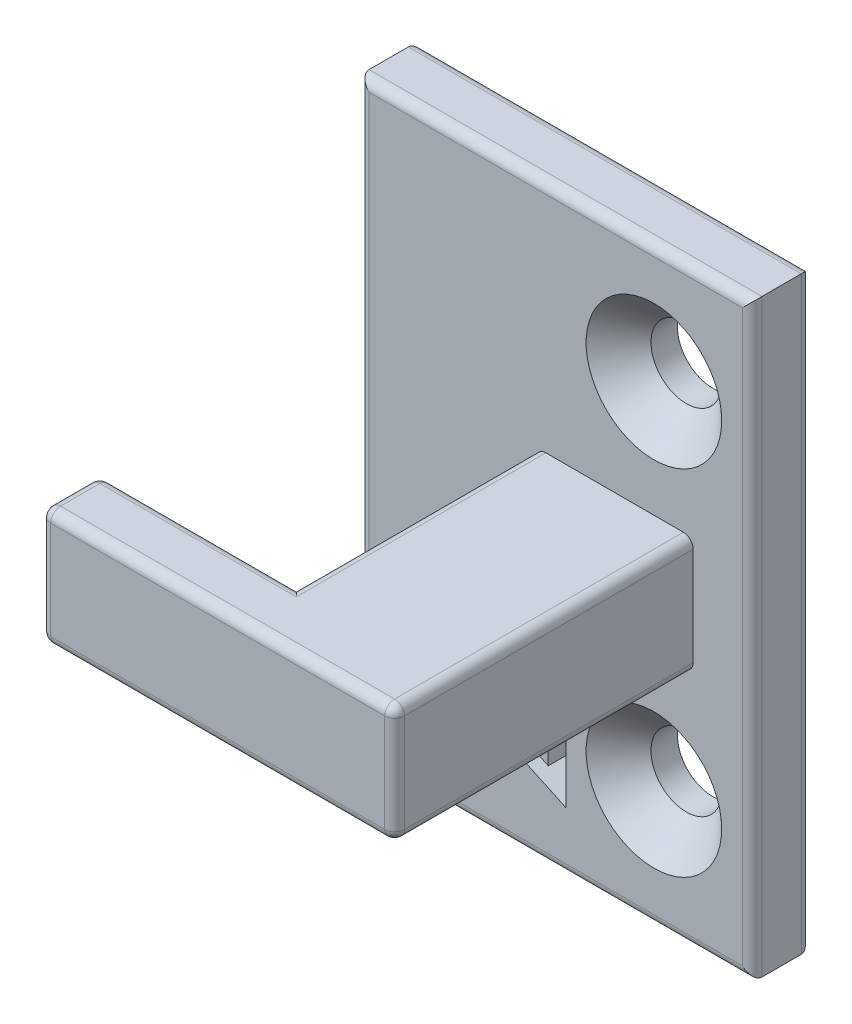
from build123d import *

# Parameters (mm, degrees)
SKETCH1_W                                           = 20
SKETCH1_H                                           = 30
BOSS_EXTRUDE1_DEPTH                                 = 3
CSK_FOR_M3_COUNTERSUNK_FLAT_HEAD_SCREW1_D           = 3.6
CSK_FOR_M3_COUNTERSUNK_FLAT_HEAD_SCREW1_DEPTH       = 20
CSK_FOR_M3_COUNTERSUNK_FLAT_HEAD_SCREW1_CSINK_D     = 6.9
CSK_FOR_M3_COUNTERSUNK_FLAT_HEAD_SCREW1_CSINK_ANGLE = 90
CSK_FOR_M3_COUNTERSUNK_FLAT_HEAD_SCREW1_TIP         = 1.081549114
SKETCH4_W                                           = 8
SKETCH4_H                                           = 6
BOSS_EXTRUDE2_DEPTH                                 = 15.2
SKETCH5_W                                           = 3
SKETCH5_H                                           = 6
BOSS_EXTRUDE3_DEPTH                                 = 10
FILLET2_R                                           = 0.5
CUT_EXTRUDE1_DEPTH                                  = 4
FILLET3_R                                           = 0.5


with BuildPart() as part:
    # Sketch1 → Boss-Extrude1 (new body)
    with BuildSketch(Plane.XY):
        Rectangle(SKETCH1_W, SKETCH1_H)
    extrude(amount=BOSS_EXTRUDE1_DEPTH)

    # CSK for M3 Countersunk Flat Head Screw1
    with Locations(Plane(origin=(5, 9, 3), x_dir=(1, 0, 0), z_dir=(0, 0, 1))):
        with Locations((0, 0), (0, -18)):
            CounterSinkHole(CSK_FOR_M3_COUNTERSUNK_FLAT_HEAD_SCREW1_D / 2, CSK_FOR_M3_COUNTERSUNK_FLAT_HEAD_SCREW1_CSINK_D / 2, depth=CSK_FOR_M3_COUNTERSUNK_FLAT_HEAD_SCREW1_DEPTH, counter_sink_angle=CSK_FOR_M3_COUNTERSUNK_FLAT_HEAD_SCREW1_CSINK_ANGLE)
            with Locations((0, 0, -(CSK_FOR_M3_COUNTERSUNK_FLAT_HEAD_SCREW1_DEPTH + CSK_FOR_M3_COUNTERSUNK_FLAT_HEAD_SCREW1_TIP / 2))):  # 118° drill point
                Cone(0, CSK_FOR_M3_COUNTERSUNK_FLAT_HEAD_SCREW1_D / 2, CSK_FOR_M3_COUNTERSUNK_FLAT_HEAD_SCREW1_TIP, mode=Mode.SUBTRACT)

    # Sketch4 → Boss-Extrude2 (add)
    with BuildSketch(Plane.XY.offset(3)):
        with Locations((3, 0.108485118)):
            Rectangle(SKETCH4_W, SKETCH4_H)
    extrude(amount=BOSS_EXTRUDE2_DEPTH)

    # Sketch5 → Boss-Extrude3 (add)
    with BuildSketch(Plane.ZY.offset(1)):
        with Locations((16.7, 0.108485118)):
            Rectangle(SKETCH5_W, SKETCH5_H)
    extrude(amount=BOSS_EXTRUDE3_DEPTH)

    # Fillet2
    fillet2_edges = [part.edges().sort_by_distance(p)[0] for p in [
        (10, 0, 3),
        (0, 15, 3),
        (7, -2.891514882, 10.6),
        (7, 3.108485118, 10.6),
        (-2, -2.891514882, 18.2),
        (7, 0.108485118, 18.2),
        (-2, 3.108485118, 18.2),
        (-1, 3.108485118, 9.1),
        (-10, 0, 3),
        (-1, -2.891514882, 9.1),
        (-6, 3.108485118, 15.2),
        (-6, -2.891514882, 15.2),
        (0, 15, 0),
        (10, 0, 0),
        (0, -15, 0),
        (-10, 0, 0),
        (0, -15, 3),
    ]]
    fillet(fillet2_edges, radius=FILLET2_R)

    # Sketch6 → Cut-Extrude1 (cut, through all)
    with BuildSketch(Plane.XY.offset(3)):
        Polygon((-0.377386615, -7.652187056), (0.53847877, -7.652187056), (0.53847877, -12.027988338), (-6.483155845, -8.750907509), (-6.483155845, -11.926225518), (-7.39902123, -11.926225518), (-7.39902123, -7.346898595), (-0.377386615, -10.625569468), align=None)
    extrude(amount=-CUT_EXTRUDE1_DEPTH, mode=Mode.SUBTRACT)

    # Fillet3
    fillet3_edges = [part.edges().sort_by_distance(p)[0] for p in [
        (-11, -2.891514882, 16.7),
        (-11, 0.108485118, 15.2),
        (-11, 0.108485118, 18.2),
        (-11, 3.108485118, 16.7),
        (-11, 2.962038509, 15.346446609),
        (-11, 2.962038509, 18.053553391),
        (-11, -2.745068272, 18.053553391),
        (-11, -2.745068272, 15.346446609),
    ]]
    fillet(fillet3_edges, radius=FILLET3_R)


solid = part.part
